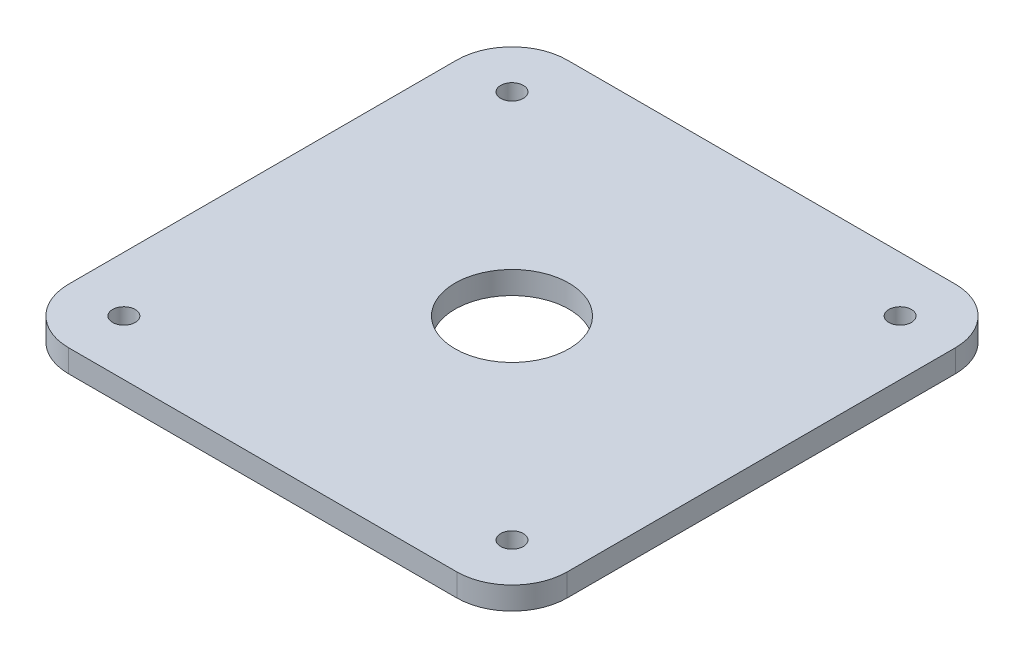
from build123d import *

# Parameters (mm, degrees)
CROQUIS1_R              = 32
CROQUIS1_R_2            = 6.35
SALIENTE_EXTRUIR1_DEPTH = 12.7


with BuildPart() as part:
    # Croquis1 → Saliente-Extruir1 (new body)
    with BuildSketch(Plane(origin=(0, 0, 0), x_dir=(1, 0, 0), z_dir=(0, 1, 0))):
        with BuildLine():
            Line((-109, 140), (109, 140))
            ThreePointArc((109, 140), (130.920310217, 130.920310217), (140, 109))
            Line((140, 109), (140, -109))
            ThreePointArc((140, -109), (130.920310217, -130.920310217), (109, -140))
            Line((109, -140), (-109, -140))
            ThreePointArc((-109, -140), (-130.920310217, -130.920310217), (-140, -109))
            Line((-140, -109), (-140, 109))
            ThreePointArc((-140, 109), (-130.920310217, 130.920310217), (-109, 140))
        make_face()
        Circle(CROQUIS1_R, mode=Mode.SUBTRACT)
        with Locations((-109, 109)):
            Circle(CROQUIS1_R_2, mode=Mode.SUBTRACT)
        with Locations((109, 109)):
            Circle(CROQUIS1_R_2, mode=Mode.SUBTRACT)
        with Locations((109, -109)):
            Circle(CROQUIS1_R_2, mode=Mode.SUBTRACT)
        with Locations((-109, -109)):
            Circle(CROQUIS1_R_2, mode=Mode.SUBTRACT)
    extrude(amount=SALIENTE_EXTRUIR1_DEPTH)


solid = part.part
